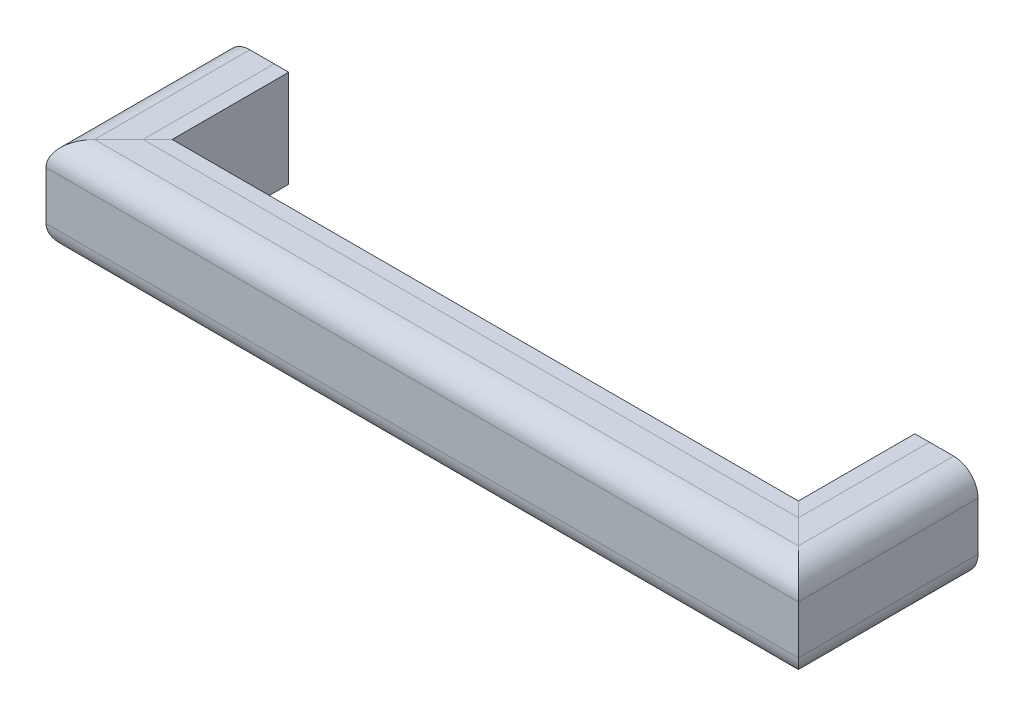
from build123d import *


with BuildPart() as part:
    # Sweep1: sweep along a path in Sketch2
    with BuildLine(Plane(origin=(0, 0, 0), x_dir=(1, 0, 0), z_dir=(0, 1, 0))) as sweep1_path:
        Line((-409.575, 0), (-409.575, -152.4))
        Line((-409.575, -152.4), (409.575, -152.4))
        Line((409.575, -152.4), (409.575, 0))
    # Sketch1 → Sweep1 (sweep)
    with BuildSketch(Plane.XY):
        with BuildLine():
            Line((-428.625, 127), (-460.375, 127))
            ThreePointArc((-460.375, 127), (-482.825640303, 117.700640303), (-492.125, 95.25))
            Line((-492.125, 95.25), (-492.125, 31.75))
            ThreePointArc((-492.125, 31.75), (-482.825640303, 9.299359697), (-460.375, 0))
            Line((-460.375, 0), (-428.625, 0))
            Line((-428.625, 0), (-409.575, 0))
            Line((-409.575, 0), (-409.575, 127))
            Line((-409.575, 127), (-428.625, 127))
        make_face()
    sweep(path=sweep1_path.line, transition=Transition.RIGHT)


solid = part.part
